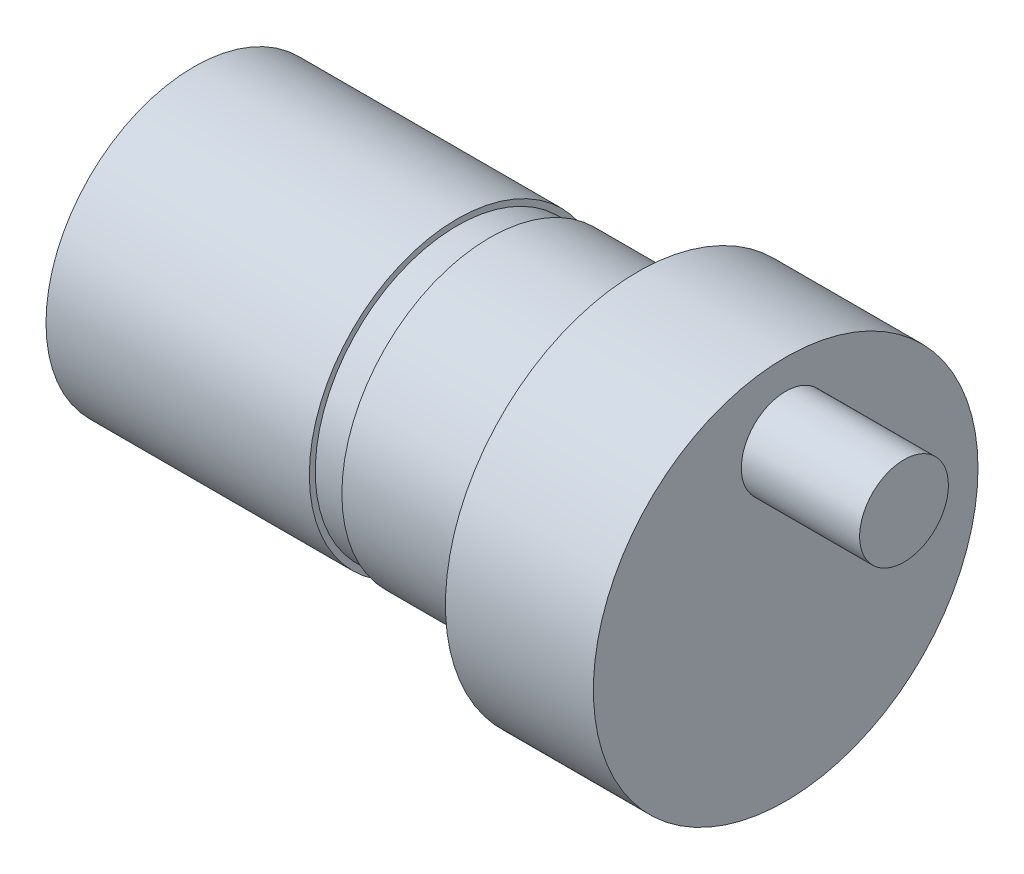
from build123d import *

# Parameters (mm, degrees)
SKETCH1_R           = 6.5
BOSS_EXTRUDE1_DEPTH = 5
SKETCH2_R           = 5
BOSS_EXTRUDE2_DEPTH = 15
SKETCH3_R           = 1.5
BOSS_EXTRUDE3_DEPTH = 4
SKETCH4_W           = 1.1
SKETCH4_H           = 0.2


with BuildPart() as part:
    # Sketch1 → Boss-Extrude1 (new body)
    with BuildSketch(Plane(origin=(0, 0, 0), x_dir=(0, 0, -1), z_dir=(1, 0, 0))):
        Circle(SKETCH1_R)
    extrude(amount=BOSS_EXTRUDE1_DEPTH)

    # Sketch2 → Boss-Extrude2 (add)
    with BuildSketch(Plane.ZY):
        Circle(SKETCH2_R)
    extrude(amount=BOSS_EXTRUDE2_DEPTH)

    # Sketch3 → Boss-Extrude3 (add)
    with BuildSketch(Plane(origin=(5, 0, 0), x_dir=(0, 0, -1), z_dir=(1, 0, 0))):
        with Locations((0, 4)):
            Circle(SKETCH3_R)
    extrude(amount=BOSS_EXTRUDE3_DEPTH)

    # Sketch4 → Cut-Revolve1 (revolve, cut)
    with BuildSketch(Plane.XY):
        with Locations((-5.55, 4.9)):
            Rectangle(SKETCH4_W, SKETCH4_H)
    revolve(axis=Axis((-1.178470482, 0, 0), (-1, 0, 0)), mode=Mode.SUBTRACT)


solid = part.part
